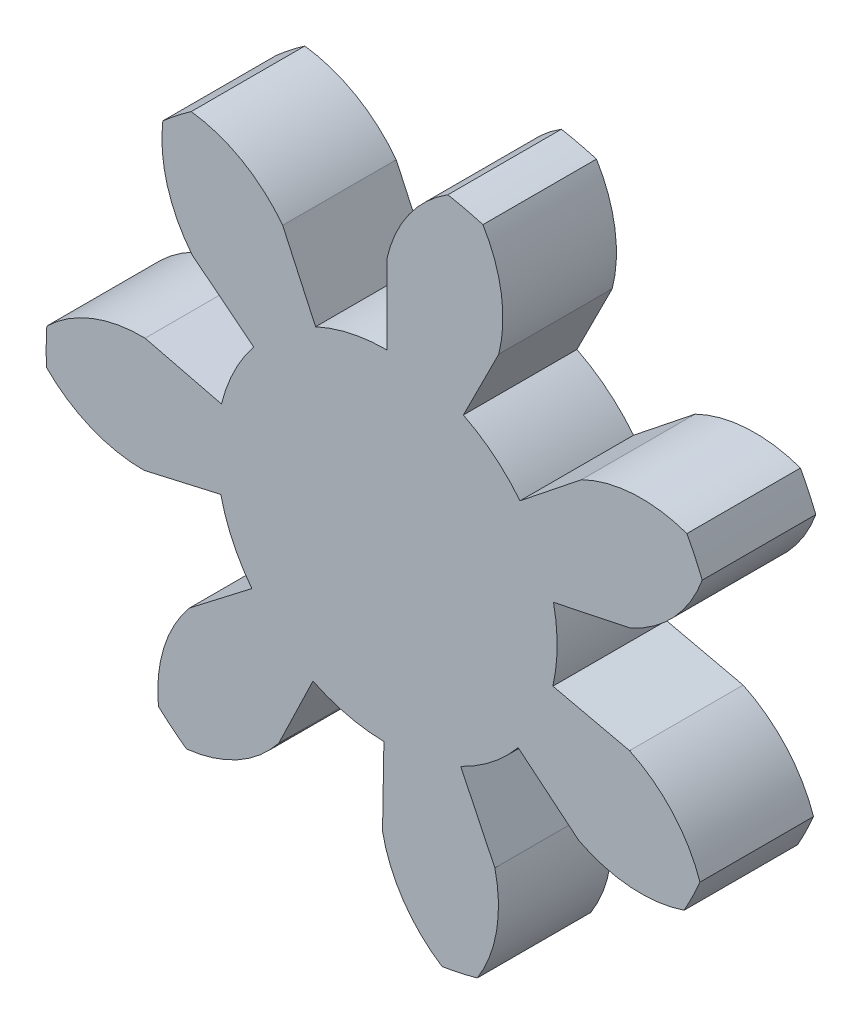
from build123d import *

# Parameters (mm, degrees)
BOSS_EXTRU_1_DEPTH           = 3
R_P_TITION_CIRCULAIRE2_COUNT = 7
ESQUISSE5_R                  = 4.5
BOSS_EXTRU_2_DEPTH           = 3


with BuildPart() as part:
    # Esquisse4 → Boss.-Extru.1 (new body)
    with BuildSketch(Plane.XY):
        with BuildLine():
            Line((0, 6.577848346), (0, 4.5))
            ThreePointArc((0, 4.5), (1.039097311, 4.378387463), (2.022031395, 4.020123013))
            Line((2.022031395, 4.020123013), (2.955692415, 5.876391002))
            ThreePointArc((2.955692415, 5.876391002), (3.02541978, 7.297456647), (2.538901994, 8.634464469))
            ThreePointArc((2.538901994, 8.634464469), (2.078194622, 8.756774927), (1.611657757, 8.854521968))
            ThreePointArc((1.611657757, 8.854521968), (0.576250392, 7.878703818), (0, 6.577848346))
        make_face()
    extrude(amount=BOSS_EXTRU_1_DEPTH)


with BuildPart() as r_p_tition_circulaire2_1:
    # Répétition circulaire2: pattern copy
    add(part.part.rotate(Axis((0, 0, 0), (0, 0, 1)), 1 * 360 / R_P_TITION_CIRCULAIRE2_COUNT))


with BuildPart() as r_p_tition_circulaire2_2:
    # Répétition circulaire2: pattern copy
    add(part.part.rotate(Axis((0, 0, 0), (0, 0, 1)), 2 * 360 / R_P_TITION_CIRCULAIRE2_COUNT))


with BuildPart() as r_p_tition_circulaire2_3:
    # Répétition circulaire2: pattern copy
    add(part.part.rotate(Axis((0, 0, 0), (0, 0, 1)), 3 * 360 / R_P_TITION_CIRCULAIRE2_COUNT))


with BuildPart() as r_p_tition_circulaire2_4:
    # Répétition circulaire2: pattern copy
    add(part.part.rotate(Axis((0, 0, 0), (0, 0, 1)), 4 * 360 / R_P_TITION_CIRCULAIRE2_COUNT))


with BuildPart() as r_p_tition_circulaire2_5:
    # Répétition circulaire2: pattern copy
    add(part.part.rotate(Axis((0, 0, 0), (0, 0, 1)), 5 * 360 / R_P_TITION_CIRCULAIRE2_COUNT))


with BuildPart() as r_p_tition_circulaire2_6:
    # Répétition circulaire2: pattern copy
    add(part.part.rotate(Axis((0, 0, 0), (0, 0, 1)), 6 * 360 / R_P_TITION_CIRCULAIRE2_COUNT))


with BuildPart() as part_1:
    add(part.part)

    add(r_p_tition_circulaire2_1.part)  # Boss.-Extru.2 merges Répétition circulaire2_1

    add(r_p_tition_circulaire2_2.part)  # Boss.-Extru.2 merges Répétition circulaire2_2

    add(r_p_tition_circulaire2_3.part)  # Boss.-Extru.2 merges Répétition circulaire2_3

    add(r_p_tition_circulaire2_4.part)  # Boss.-Extru.2 merges Répétition circulaire2_4

    add(r_p_tition_circulaire2_5.part)  # Boss.-Extru.2 merges Répétition circulaire2_5

    add(r_p_tition_circulaire2_6.part)  # Boss.-Extru.2 merges Répétition circulaire2_6
    # Esquisse5 → Boss.-Extru.2 (add)
    with BuildSketch(Plane.XY):
        Circle(ESQUISSE5_R)
    extrude(amount=BOSS_EXTRU_2_DEPTH)


solid = part_1.part
